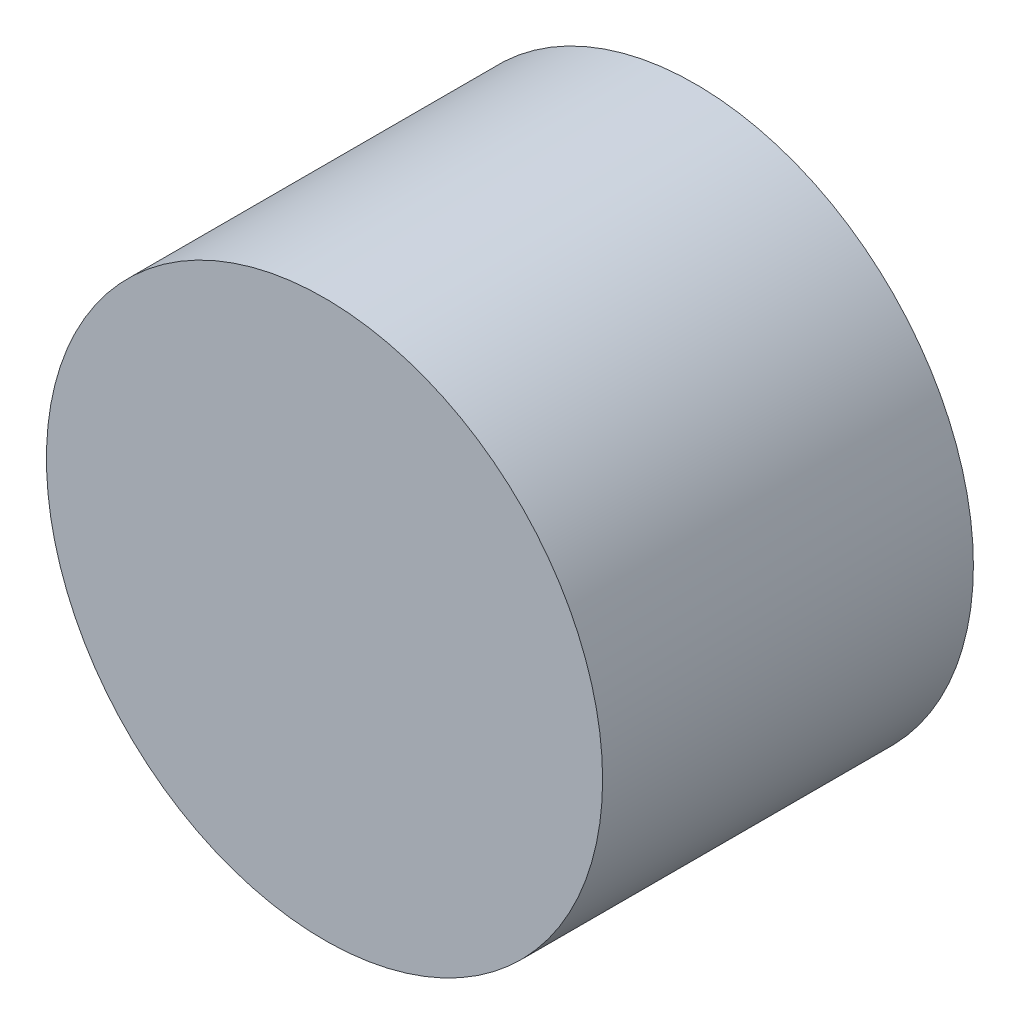
from build123d import *

# Parameters (mm, degrees)
ESQUISSE1_R      = 1.5
EXTRUSION1_DEPTH = 2


with BuildPart() as part:
    # Esquisse1 → Extrusion1 (new body)
    with BuildSketch(Plane.XY):
        Circle(ESQUISSE1_R)
    extrude(amount=EXTRUSION1_DEPTH)


solid = part.part
